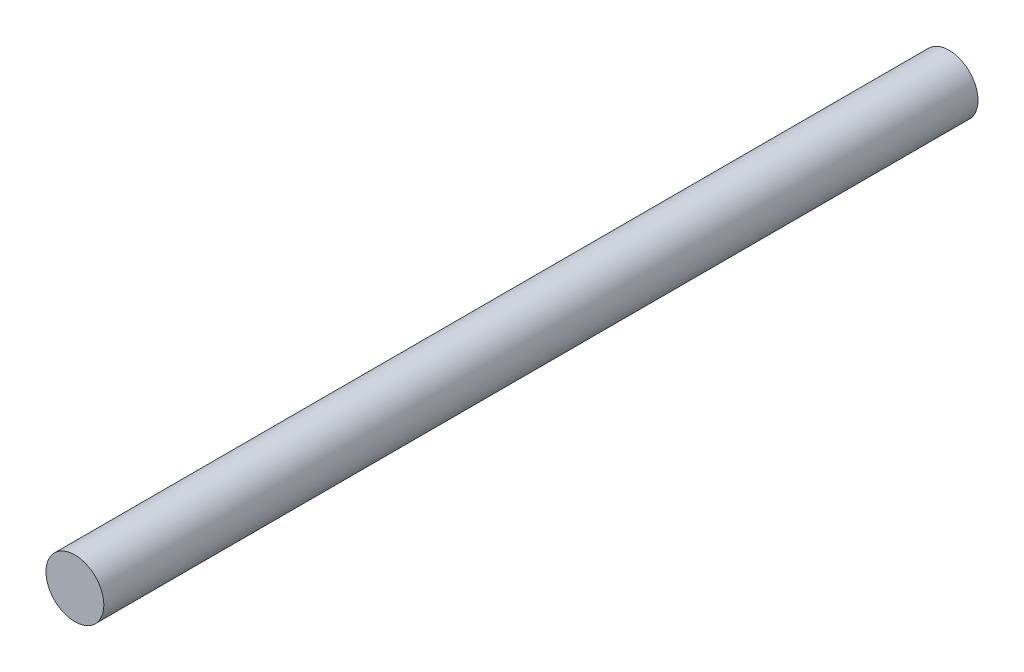
from build123d import *

# Parameters (mm, degrees)
SKETCH_1_R           = 5
EXTRUDE_1_DEPTH      = 25
EXTRUDE_1_DEPTH_BACK = 126


with BuildPart() as part:
    # Эскиз1 → Бобышка-Вытянуть1 (new body, two sides)
    with BuildSketch(Plane.XY) as extrude_1_sk:
        Circle(SKETCH_1_R)
    extrude(amount=EXTRUDE_1_DEPTH)
    extrude(extrude_1_sk.sketch, amount=-EXTRUDE_1_DEPTH_BACK)


solid = part.part
